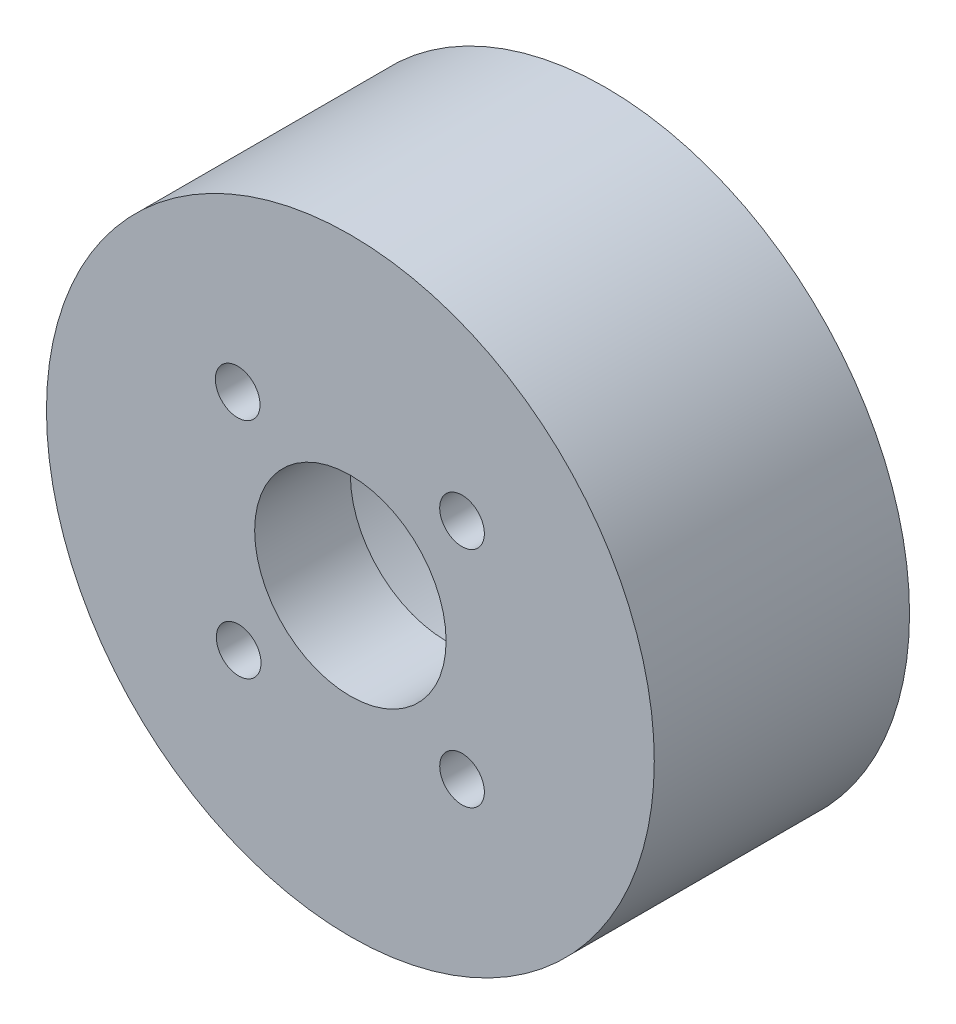
from build123d import *

# Parameters (mm, degrees)
SKETCH1_R           = 19.05
BOSS_EXTRUDE1_DEPTH = 16
SKETCH2_R           = 15.4
CUT_EXTRUDE1_DEPTH  = 10
SKETCH4_R           = 2.5
CUT_EXTRUDE3_DEPTH  = 1.4
SKETCH5_R           = 1.4
CUT_EXTRUDE4_DEPTH  = 5.6
SKETCH6_R           = 1.4
CUT_EXTRUDE5_DEPTH  = 5.6
SKETCH9_R           = 1.4
CUT_EXTRUDE8_DEPTH  = 5.6
SKETCH10_R          = 1.4
CUT_EXTRUDE9_DEPTH  = 5.6
SKETCH11_R          = 6
CUT_EXTRUDE11_DEPTH = 7


with BuildPart() as part:
    # Sketch1 → Boss-Extrude1 (new body)
    with BuildSketch(Plane.XY):
        Circle(SKETCH1_R)
    extrude(amount=BOSS_EXTRUDE1_DEPTH)

    # Sketch2 → Cut-Extrude1 (cut)
    with BuildSketch(Plane(origin=(0, 0, 0), x_dir=(-1, 0, 0), z_dir=(0, 0, -1))):
        Circle(SKETCH2_R)
    extrude(amount=-CUT_EXTRUDE1_DEPTH, mode=Mode.SUBTRACT)

    # Sketch4 → Cut-Extrude3 (cut)
    with BuildSketch(Plane(origin=(0, 0, 10), x_dir=(-1, 0, 0), z_dir=(0, 0, -1))):
        with Locations((-7, 7)):
            Circle(SKETCH4_R)
        with Locations((7, 7)):
            Circle(SKETCH4_R)
        with Locations((7, -7)):
            Circle(SKETCH4_R)
        with Locations((-7, -7)):
            Circle(SKETCH4_R)
    extrude(amount=-CUT_EXTRUDE3_DEPTH, mode=Mode.SUBTRACT)

    # Sketch5 → Cut-Extrude4 (cut, through all)
    with BuildSketch(Plane(origin=(0, 0, 11.4), x_dir=(-1, 0, 0), z_dir=(0, 0, -1))):
        with Locations((-6.998002378, 7.019977132)):
            Circle(SKETCH5_R)
    extrude(amount=-CUT_EXTRUDE4_DEPTH, mode=Mode.SUBTRACT)

    # Sketch6 → Cut-Extrude5 (cut, through all)
    with BuildSketch(Plane(origin=(0, 0, 11.4), x_dir=(-1, 0, 0), z_dir=(0, 0, -1))):
        with Locations((7.062657108, 6.986426582)):
            Circle(SKETCH6_R)
    extrude(amount=-CUT_EXTRUDE5_DEPTH, mode=Mode.SUBTRACT)

    # Sketch9 → Cut-Extrude8 (cut, through all)
    with BuildSketch(Plane(origin=(0, 0, 11.4), x_dir=(-1, 0, 0), z_dir=(0, 0, -1))):
        with Locations((-7, -7)):
            Circle(SKETCH9_R)
    extrude(amount=-CUT_EXTRUDE8_DEPTH, mode=Mode.SUBTRACT)

    # Sketch10 → Cut-Extrude9 (cut, through all)
    with BuildSketch(Plane(origin=(0, 0, 11.4), x_dir=(-1, 0, 0), z_dir=(0, 0, -1))):
        with Locations((7, -7)):
            Circle(SKETCH10_R)
    extrude(amount=-CUT_EXTRUDE9_DEPTH, mode=Mode.SUBTRACT)

    # Sketch11 → Cut-Extrude11 (cut, through all)
    with BuildSketch(Plane(origin=(0, 0, 10), x_dir=(-1, 0, 0), z_dir=(0, 0, -1))):
        Circle(SKETCH11_R)
    extrude(amount=-CUT_EXTRUDE11_DEPTH, mode=Mode.SUBTRACT)


solid = part.part
